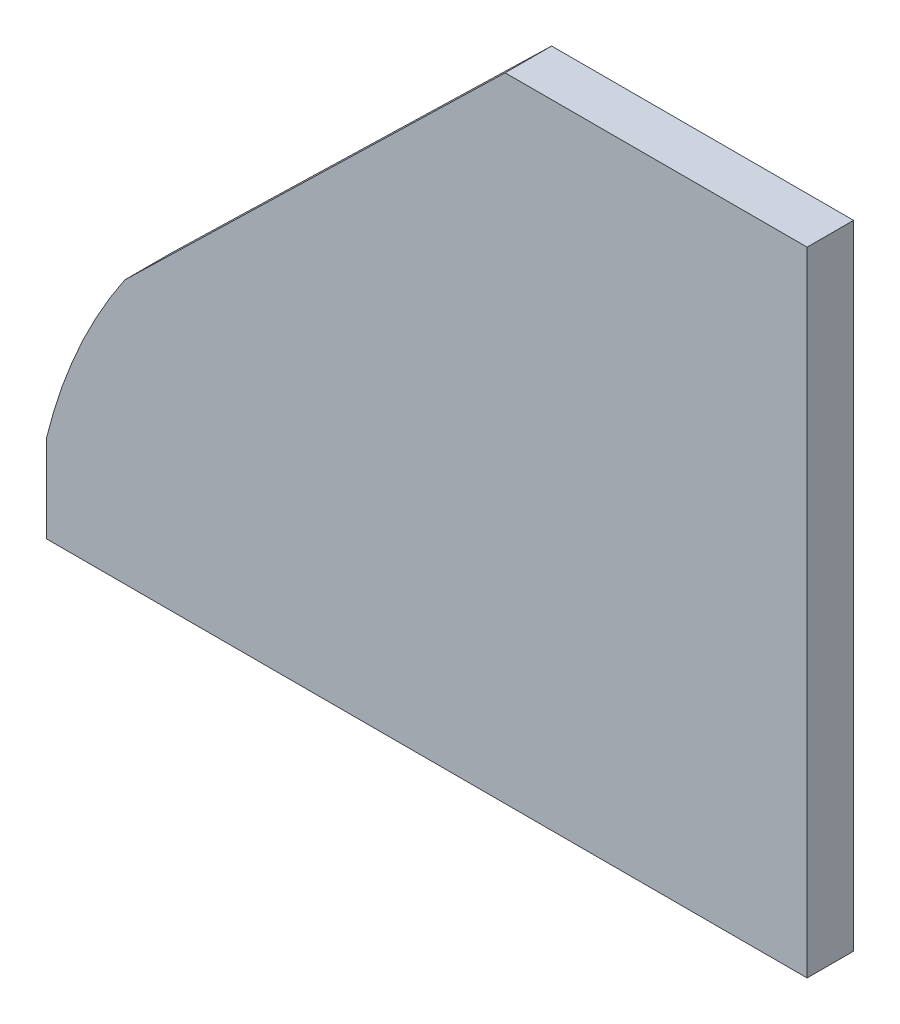
from build123d import *

# Parameters (mm, degrees)
Y_KSEKLIK_EKSTR_ZYON1_DEPTH = 8


with BuildPart() as part:
    # Çizim1 → Yükseklik-Ekstrüzyon1 (new body)
    with BuildSketch(Plane.XY):
        with BuildLine():
            Line((0, 15), (0, 0))
            Line((0, 0), (131, 0))
            Line((131, 0), (131, 109))
            Line((131, 109), (79, 109))
            Line((79, 109), (13.510611656, 45.388360721))
            ThreePointArc((13.510611656, 45.388360721), (5.385413078, 30.803232265), (0, 15))
        make_face()
    extrude(amount=Y_KSEKLIK_EKSTR_ZYON1_DEPTH)


solid = part.part
